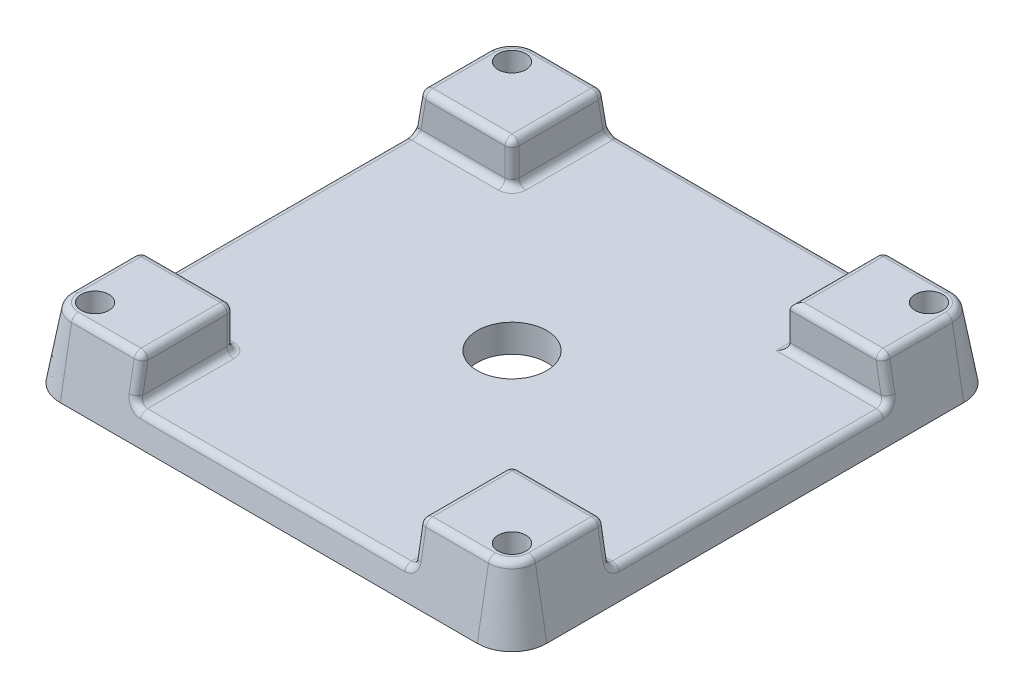
from build123d import *

# Parameters (mm, degrees)
EXTRUDE_1_DEPTH     = 10
EXTRUDE_1_TAPER     = 10
SKETCH_2_R          = 2
CUT_EXTRUDE_1_DEPTH = 26
SKETCH_3_R          = 5
CUT_EXTRUDE_2_DEPTH = 26
SKETCH_4_W          = 40
SKETCH_4_H          = 26.033800872
CUT_EXTRUDE_3_DEPTH = 50
SKETCH_6_W          = 40
SKETCH_6_H          = 33.376667785
CUT_EXTRUDE_4_DEPTH = 50
FILLET_1_R          = 1


with BuildPart() as part:
    # 草图1 → 凸台-拉伸1 (new body)
    with BuildSketch(Plane(origin=(0, 0, 0), x_dir=(1, 0, 0), z_dir=(0, 1, 0))):
        with BuildLine():
            ThreePointArc((-30, 35), (-33.535533906, 33.535533906), (-35, 30))
            Line((-35, 30), (-35, -30))
            ThreePointArc((-35, -30), (-33.535533906, -33.535533906), (-30, -35))
            Line((-30, -35), (30, -35))
            ThreePointArc((30, -35), (33.535533906, -33.535533906), (35, -30))
            Line((35, -30), (35, 30))
            ThreePointArc((35, 30), (33.535533906, 33.535533906), (30, 35))
            Line((30, 35), (-30, 35))
        make_face()
    extrude(amount=EXTRUDE_1_DEPTH, taper=EXTRUDE_1_TAPER)

    # 草图2 → 切除-拉伸1 (cut)
    with BuildSketch(Plane.XZ):
        with Locations((30, 30)):
            Circle(SKETCH_2_R)
        with Locations((-30, 30)):
            Circle(SKETCH_2_R)
        with Locations((-30, -30)):
            Circle(SKETCH_2_R)
        with Locations((30, -30)):
            Circle(SKETCH_2_R)
    extrude(amount=-CUT_EXTRUDE_1_DEPTH, mode=Mode.SUBTRACT)

    # 草图3 → 切除-拉伸2 (cut)
    with BuildSketch(Plane.XZ):
        Circle(SKETCH_3_R)
    extrude(amount=-CUT_EXTRUDE_2_DEPTH, mode=Mode.SUBTRACT)

    # 草图4 → 切除-拉伸3 (cut, symmetric)
    with BuildSketch(Plane.XY):
        with Locations((0, 17.016900436)):
            Rectangle(SKETCH_4_W, SKETCH_4_H)
    extrude(amount=CUT_EXTRUDE_3_DEPTH, both=True, mode=Mode.SUBTRACT)

    # 草图6 → 切除-拉伸4 (cut, symmetric)
    with BuildSketch(Plane(origin=(0, 0, 0), x_dir=(0, 0, -1), z_dir=(1, 0, 0))):
        with Locations((0, 20.688333893)):
            Rectangle(SKETCH_6_W, SKETCH_6_H)
    extrude(amount=CUT_EXTRUDE_4_DEPTH, both=True, mode=Mode.SUBTRACT)

    # 圆角1
    fillet_1_edges = [part.edges().sort_by_distance(p)[0] for p in [
        (32.288713868, 10, 32.288713868),
        (33.236730193, 10, 25),
        (32.288713868, 10, -32.288713868),
        (25, 10, -33.236730193),
        (-32.288713868, 10, -32.288713868),
        (-33.236730193, 10, -25),
        (-32.288713868, 10, 32.288713868),
        (25, 10, 33.236730193),
        (-25, 10, -33.236730193),
        (-20, 10, -26.618365096),
        (20, 10, 26.618365096),
        (20, 7, 33.765711135),
        (20, 7, -33.765711135),
        (-20, 4, -27.147346039),
        (-20, 7, 33.765711135),
        (-20, 7, -33.765711135),
        (20, 4, -27.147346039),
        (0, 4, 34.294692077),
        (0, 4, -34.294692077),
        (-25, 10, 33.236730193),
        (20, 4, 27.147346039),
        (-20, 4, 27.147346039),
        (-20, 10, 26.618365096),
        (20, 10, -26.618365096),
        (-33.236730193, 10, 25),
        (33.236730193, 10, -25),
        (27.147346039, 4, -20),
        (34.294692077, 4, 0),
        (-34.294692077, 4, 0),
        (-27.147346039, 4, -20),
        (33.765711135, 7, -20),
        (-33.765711135, 7, -20),
        (-20, 7, -20),
        (27.147346039, 4, 20),
        (33.765711135, 7, 20),
        (20, 7, 20),
        (-33.765711135, 7, 20),
        (-27.147346039, 4, 20),
        (-20, 7, 20),
        (26.618365096, 10, -20),
        (-26.618365096, 10, -20),
        (-26.618365096, 10, 20),
        (26.618365096, 10, 20),
    ]]
    fillet(fillet_1_edges, radius=FILLET_1_R)


solid = part.part
